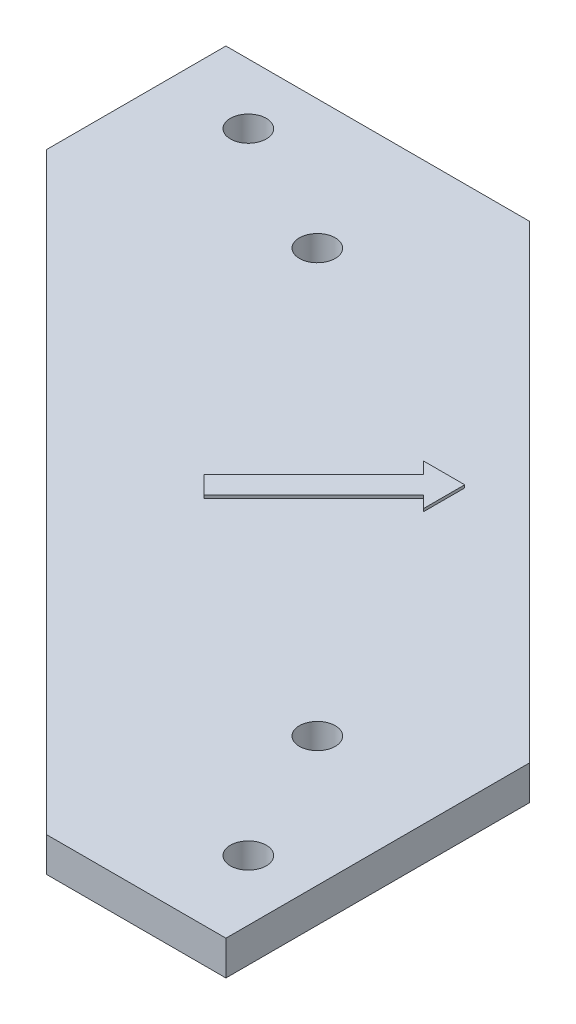
from build123d import *

# Parameters (mm, degrees)
SKETCH1_R           = 1.651
BOSS_EXTRUDE2_DEPTH = 3.175
BOSS_EXTRUDE3_DEPTH = 0.254


with BuildPart() as part:
    # Sketch1 → Boss-Extrude2 (new body)
    with BuildSketch(Plane(origin=(0, 0, 0), x_dir=(1, 0, 0), z_dir=(0, 1, 0))):
        Polygon((0, -43.18), (-43.18, 0), (-71.12, 0), (-71.12, -16.51), (-16.51, -71.12), (0, -71.12), align=None)
        with Locations((-5.55605696, -63.5)):
            Circle(SKETCH1_R, mode=Mode.SUBTRACT)
        with Locations((-11.905836488, -50.8)):
            Circle(SKETCH1_R, mode=Mode.SUBTRACT)
        with Locations((-63.5, -5.55605696)):
            Circle(SKETCH1_R, mode=Mode.SUBTRACT)
        with Locations((-50.8, -11.905836488)):
            Circle(SKETCH1_R, mode=Mode.SUBTRACT)
    extrude(amount=BOSS_EXTRUDE2_DEPTH)

    # Sketch5 → Boss-Extrude3 (add)
    with BuildSketch(Plane(origin=(0, 3.175, 0), x_dir=(1, 0, 0), z_dir=(0, 1, 0))):
        Polygon((-24.899422015, -24.239032228), (-28.709422015, -24.239032228), (-27.63179128, -25.316662963), (-37.727112803, -35.411984485), (-36.072374272, -37.066723016), (-25.977052749, -26.971401493), (-24.899422015, -28.049032228), align=None)
    extrude(amount=BOSS_EXTRUDE3_DEPTH)


solid = part.part
